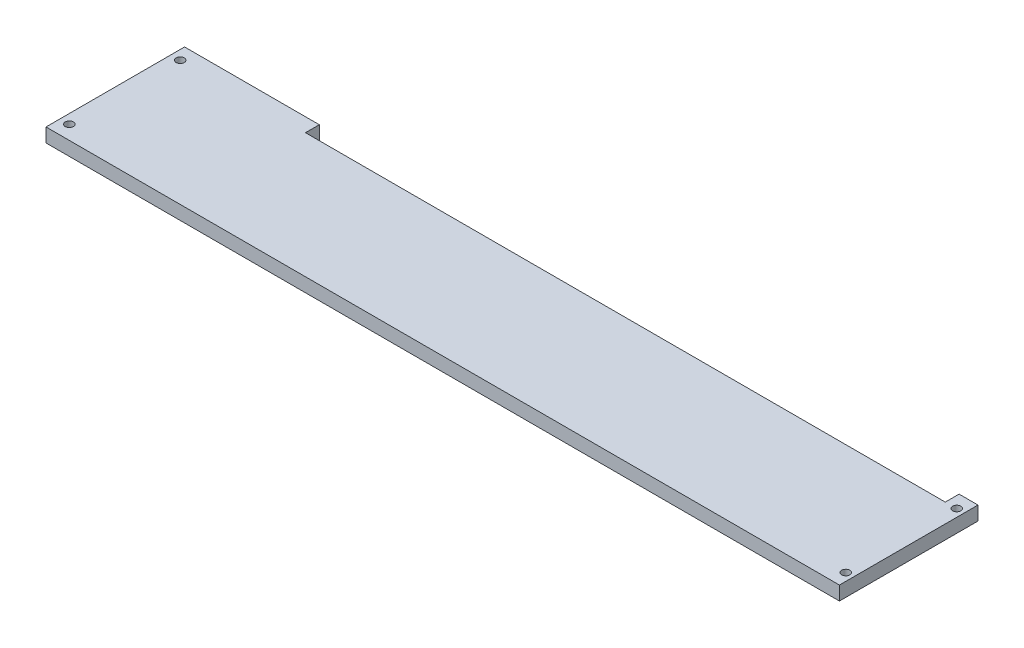
from build123d import *

# Parameters (mm, degrees)
BOSS_EXTRUDE1_DEPTH = 9.55
CUT_EXTRUDE1_REACH  = 11.55
SKETCH2_R           = 2.795
SKETCH5_R           = 4.61
CUT_EXTRUDE3_DEPTH  = 5.2


with BuildPart() as part:
    # Sketch1 → Boss-Extrude1 (new body)
    with BuildSketch(Plane(origin=(0, 0, 0), x_dir=(1, 0, 0), z_dir=(0, 1, 0))):
        Polygon((532.64, 0), (545.64, 0), (545.64, -95.3), (0, -95.3), (0, 0), (92.64, 0), (92.64, -9.5), (532.64, -9.5), align=None)
    extrude(amount=BOSS_EXTRUDE1_DEPTH)

    # Sketch2 → Cut-Extrude1 (cut, up to next)
    with BuildSketch(Plane(origin=(0, 9.55, 0), x_dir=(-1, 0, 0), z_dir=(0, 1, 0)), mode=Mode.PRIVATE) as cut_extrude1_sk1:
        with Locations((-6.4, 9.38)):
            Circle(SKETCH2_R)
    cut_extrude1_tool1 = extrude(cut_extrude1_sk1.sketch, amount=-CUT_EXTRUDE1_REACH, mode=Mode.PRIVATE) & part.part
    add(cut_extrude1_tool1.solids().sort_by_distance((6.4, 9.55, 9.38))[0], mode=Mode.SUBTRACT)
    # Sketch2 → Cut-Extrude1 (cut, up to next)
    with BuildSketch(Plane(origin=(0, 9.55, 0), x_dir=(-1, 0, 0), z_dir=(0, 1, 0)), mode=Mode.PRIVATE) as cut_extrude1_sk2:
        with Locations((-6.4, 85.68)):
            Circle(SKETCH2_R)
    cut_extrude1_tool2 = extrude(cut_extrude1_sk2.sketch, amount=-CUT_EXTRUDE1_REACH, mode=Mode.PRIVATE) & part.part
    add(cut_extrude1_tool2.solids().sort_by_distance((6.4, 9.55, 85.68))[0], mode=Mode.SUBTRACT)
    # Sketch2 → Cut-Extrude1 (cut, up to next)
    with BuildSketch(Plane(origin=(0, 9.55, 0), x_dir=(-1, 0, 0), z_dir=(0, 1, 0)), mode=Mode.PRIVATE) as cut_extrude1_sk3:
        with Locations((-540.4, 85.68)):
            Circle(SKETCH2_R)
    cut_extrude1_tool3 = extrude(cut_extrude1_sk3.sketch, amount=-CUT_EXTRUDE1_REACH, mode=Mode.PRIVATE) & part.part
    add(cut_extrude1_tool3.solids().sort_by_distance((540.4, 9.55, 85.68))[0], mode=Mode.SUBTRACT)
    # Sketch2 → Cut-Extrude1 (cut, up to next)
    with BuildSketch(Plane(origin=(0, 9.55, 0), x_dir=(-1, 0, 0), z_dir=(0, 1, 0)), mode=Mode.PRIVATE) as cut_extrude1_sk4:
        with Locations((-540.4, 9.38)):
            Circle(SKETCH2_R)
    cut_extrude1_tool4 = extrude(cut_extrude1_sk4.sketch, amount=-CUT_EXTRUDE1_REACH, mode=Mode.PRIVATE) & part.part
    add(cut_extrude1_tool4.solids().sort_by_distance((540.4, 9.55, 9.38))[0], mode=Mode.SUBTRACT)

    # Sketch5 → Cut-Extrude3 (cut)
    with BuildSketch(Plane.XZ):
        with Locations((6.4, 85.68)):
            Circle(SKETCH5_R)
        with Locations((6.4, 9.38)):
            Circle(SKETCH5_R)
        with Locations((540.4, 9.38)):
            Circle(SKETCH5_R)
        with Locations((540.4, 85.68)):
            Circle(SKETCH5_R)
    extrude(amount=-CUT_EXTRUDE3_DEPTH, mode=Mode.SUBTRACT)


solid = part.part
